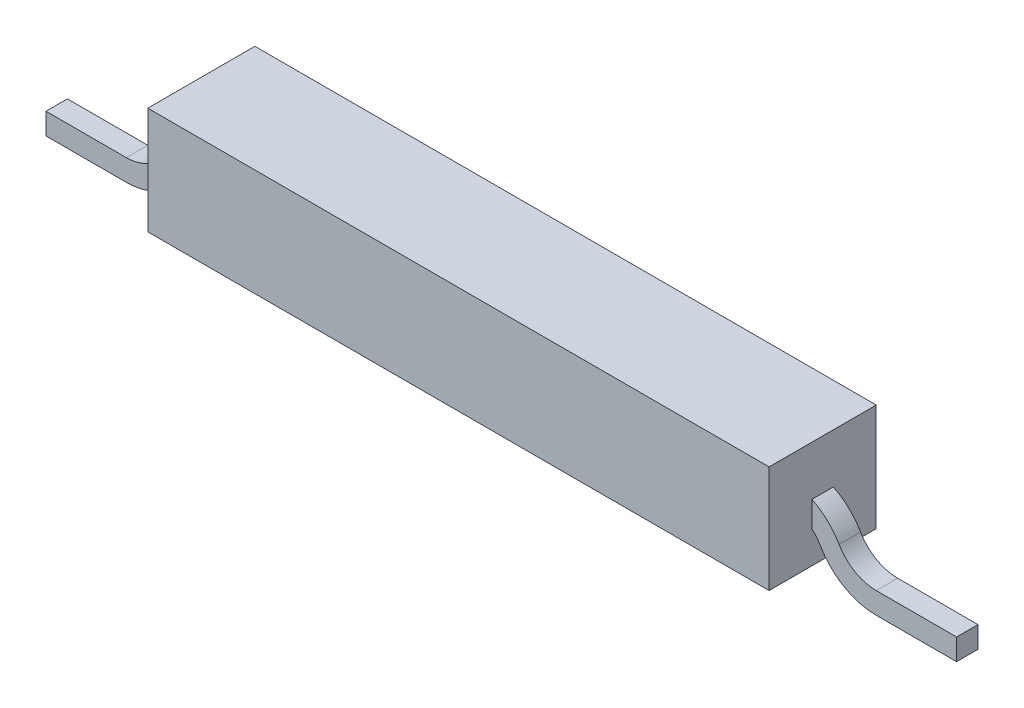
from build123d import *

# Parameters (mm, degrees)
ESQUISSE6_W        = 2
ESQUISSE6_H        = 2
BOSS_EXTRU_3_DEPTH = 5.8
ESQUISSE7_W        = 0.4
ESQUISSE7_H        = 0.4


with BuildPart() as part:
    # Esquisse6 → Boss.-Extru.3 (new body, symmetric)
    with BuildSketch(Plane(origin=(0, 0, 0), x_dir=(0, 0, -1), z_dir=(1, 0, 0))):
        Rectangle(ESQUISSE6_W, ESQUISSE6_H)
    extrude(amount=BOSS_EXTRU_3_DEPTH, both=True)

    # Balayage1: sweep along a path in Esquisse2
    with BuildLine(Plane.XY) as balayage1_path:
        Line((-8.5, -1), (-7, -1))
        ThreePointArc((-7, -1), (-6.5, -0.866025404), (-6.133974596, -0.5))
        ThreePointArc((-6.133974596, -0.5), (-5.767949192, -0.133974596), (-5.267949192, 0))
        Line((-5.267949192, 0), (5.267949192, 0))
        ThreePointArc((5.267949192, 0), (5.767949192, -0.133974596), (6.133974596, -0.5))
        ThreePointArc((6.133974596, -0.5), (6.5, -0.866025404), (7, -1))
        Line((7, -1), (8.5, -1))
    # Esquisse7 → Balayage1 (sweep)
    with BuildSketch(Plane(origin=(8.5, 0, 0), x_dir=(0, 0, -1), z_dir=(1, 0, 0))):
        with Locations((0, -1)):
            Rectangle(ESQUISSE7_W, ESQUISSE7_H)
    sweep(path=balayage1_path.line)


solid = part.part
